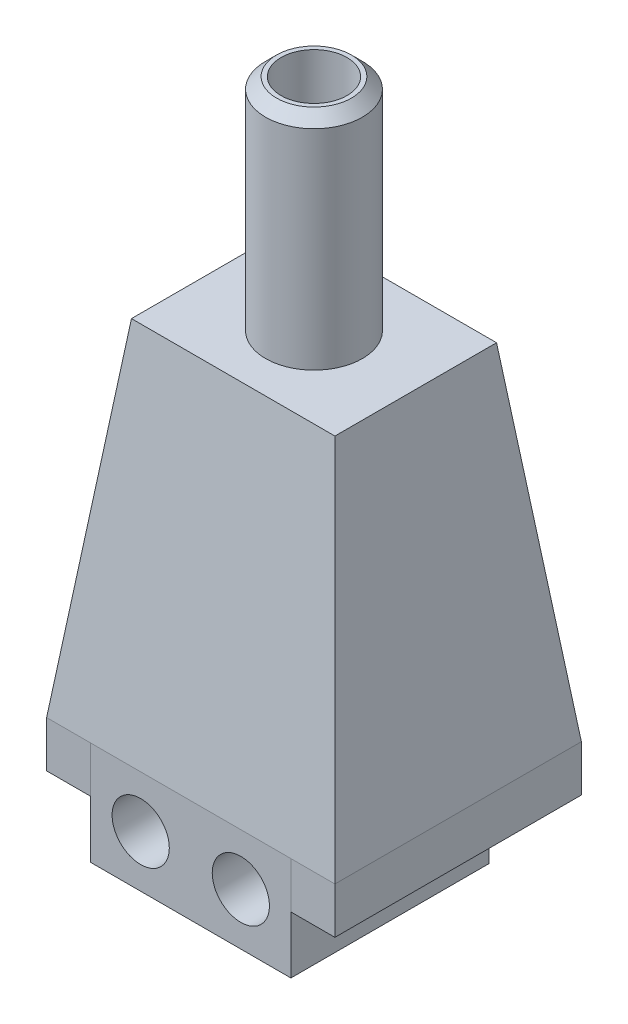
from build123d import *

# Parameters (mm, degrees)
ESBO_O1_W                = 9.1
ESBO_O1_H                = 9
RESSALTO_EXTRUS_O1_DEPTH = 4.7
ESBO_O2_W                = 13.1
ESBO_O2_H                = 11.2
RESSALTO_EXTRUS_O2_DEPTH = 15.7
RESSALTO_EXTRUS_O2_TAPER = 7
ESBO_O3_R                = 2.2
RESSALTO_EXTRUS_O3_DEPTH = 10
CASCA1_T                 = -0.7
CHANFRO1_SIZE            = 0.5
ESBO_O4_R                = 1.3
CORTE_EXTRUS_O1_DEPTH    = 2
RESSALTO_EXTRUS_O4_DEPTH = 2.1


with BuildPart() as part:
    # Esboço1 → Ressalto-extrusão1 (new body)
    with BuildSketch(Plane(origin=(0, 0, 0), x_dir=(1, 0, 0), z_dir=(0, 1, 0))):
        Rectangle(ESBO_O1_W, ESBO_O1_H)
    extrude(amount=RESSALTO_EXTRUS_O1_DEPTH)

    # Esboço4 → Corte-extrusão1 (cut)
    with BuildSketch(Plane.XY.offset(4.5)):
        with Locations((-2.275, 2.35)):
            Circle(ESBO_O4_R)
        with Locations(Location((2.275, 2.35, 0), (0, 0, 180))):
            Circle(ESBO_O4_R)
    extrude(amount=-CORTE_EXTRUS_O1_DEPTH, mode=Mode.SUBTRACT)


with BuildPart() as body_2:
    # Esboço2 → Ressalto-extrusão2 (new body)
    with BuildSketch(Plane(origin=(0, 4.7, 0), x_dir=(1, 0, 0), z_dir=(0, 1, 0))):
        with Locations((0, 1.1)):
            Rectangle(ESBO_O2_W, ESBO_O2_H)
    extrude(amount=RESSALTO_EXTRUS_O2_DEPTH, taper=RESSALTO_EXTRUS_O2_TAPER)

    # Esboço3 → Ressalto-extrusão3 (add)
    with BuildSketch(Plane(origin=(0, 20.4, 0), x_dir=(1, 0, 0), z_dir=(0, 1, 0))):
        with Locations(Location((0, 1.1, 0), (0, 0, 270))):
            Circle(ESBO_O3_R)
    extrude(amount=RESSALTO_EXTRUS_O3_DEPTH)

    # Casca1
    casca1_openings = [body_2.faces().sort_by_distance(p)[0] for p in [
        (0, 30.4, -1.1),
    ]]
    offset(amount=CASCA1_T, openings=casca1_openings, kind=Kind.INTERSECTION)

    # Chanfro1
    chanfro1_edges = [body_2.edges().sort_by_distance(p)[0] for p in [
        (0, 30.4, -3.3),
    ]]
    chamfer(chanfro1_edges, length=CHANFRO1_SIZE)


with BuildPart() as body_3:
    # Esboço5 → Ressalto-extrusão4 (new body)
    with BuildSketch(Plane.XZ.offset(-4.7)):
        Polygon((-4.55, 4.5), (-6.55, 4.5), (-6.55, -6.7), (6.55, -6.7), (6.55, 4.5), (4.55, 4.5), (4.55, -4.5), (-4.55, -4.5), align=None)
    extrude(amount=RESSALTO_EXTRUS_O4_DEPTH)


solid = Compound([part.part, body_2.part, body_3.part])
